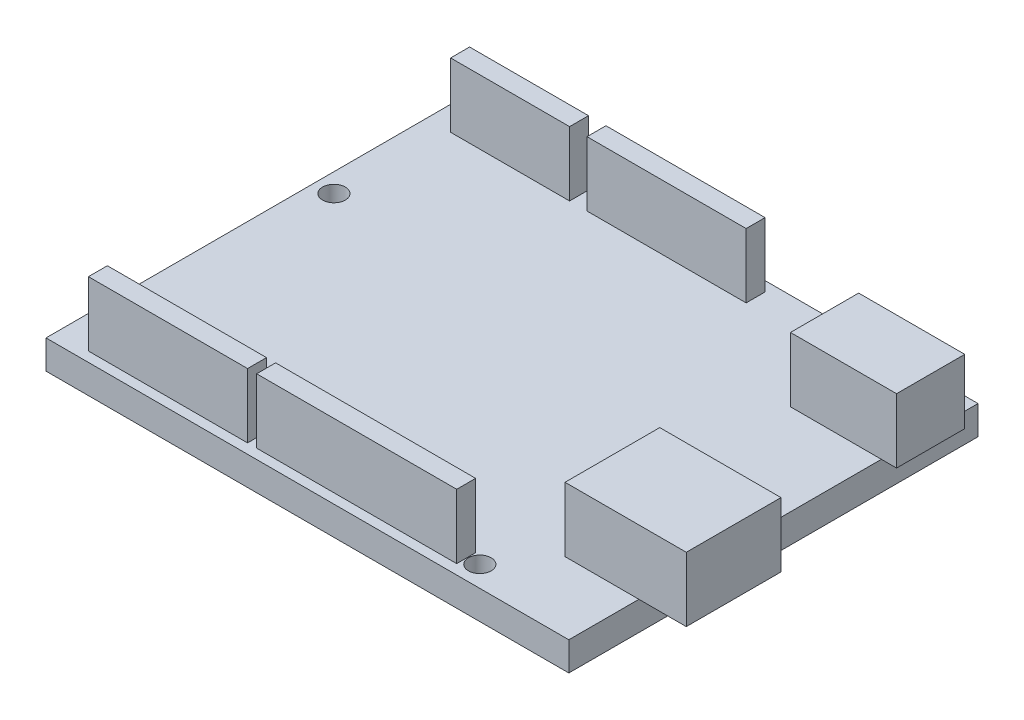
from build123d import *

# Parameters (mm, degrees)
SKETCH1_W           = 69
SKETCH1_H           = 54
SKETCH1_R           = 1.5
BOSS_EXTRUDE1_DEPTH = 3.8
SKETCH2_W           = 16
SKETCH2_H           = 12.5
SKETCH2_W_2         = 14
SKETCH2_H_2         = 9
SKETCH2_W_3         = 21
SKETCH2_H_3         = 2.5
SKETCH2_W_4         = 26.4
SKETCH2_W_5         = 15.7
BOSS_EXTRUDE2_DEPTH = 8.5


with BuildPart() as part:
    # Sketch1 → Boss-Extrude1 (new body)
    with BuildSketch(Plane(origin=(0, 0, 0), x_dir=(1, 0, 0), z_dir=(0, 1, 0))):
        with Locations((0, 27)):
            Rectangle(SKETCH1_W, SKETCH1_H)
        with Locations((-32, 7.5)):
            Circle(SKETCH1_R, mode=Mode.SUBTRACT)
        with Locations((-32, 35.5)):
            Circle(SKETCH1_R, mode=Mode.SUBTRACT)
        with Locations((19, 51.5)):
            Circle(SKETCH1_R, mode=Mode.SUBTRACT)
        with Locations((20, 2.75)):
            Circle(SKETCH1_R, mode=Mode.SUBTRACT)
    extrude(amount=BOSS_EXTRUDE1_DEPTH)

    # Sketch2 → Boss-Extrude2 (add)
    with BuildSketch(Plane(origin=(0, 3.8, 0), x_dir=(1, 0, 0), z_dir=(0, 1, 0))):
        with Locations((32.75, 15.5)):
            Rectangle(SKETCH2_W, SKETCH2_H)
        with Locations((29.5, 45.75)):
            Rectangle(SKETCH2_W_2, SKETCH2_H_2)
        with Locations((-19.7, 2.55)):
            Rectangle(SKETCH2_W_3, SKETCH2_H_3)
        with Locations((5.2, 2.55)):
            Rectangle(SKETCH2_W_4, SKETCH2_H_3)
        with Locations((-23.45, 51.45)):
            Rectangle(SKETCH2_W_5, SKETCH2_H_3)
        with Locations((-2.8, 51.45)):
            Rectangle(SKETCH2_W_3, SKETCH2_H_3)
    extrude(amount=BOSS_EXTRUDE2_DEPTH)


solid = part.part
